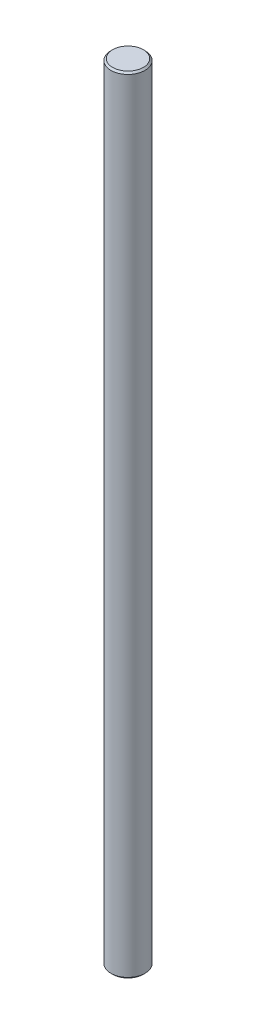
from build123d import *

# Parameters (mm, degrees)
SKETCH1_R           = 5
BOSS_EXTRUDE1_DEPTH = 230
CHAMFER1_SIZE       = 0.5


with BuildPart() as part:
    # Sketch1 → Boss-Extrude1 (new body)
    with BuildSketch(Plane(origin=(0, 0, 0), x_dir=(1, 0, 0), z_dir=(0, 1, 0))):
        Circle(SKETCH1_R)
    extrude(amount=BOSS_EXTRUDE1_DEPTH)

    # Chamfer1
    chamfer1_edges = [part.edges().sort_by_distance(p)[0] for p in [
        (-5, 0, 0),
        (-5, 230, 0),
    ]]
    chamfer(chamfer1_edges, length=CHAMFER1_SIZE)


solid = part.part
